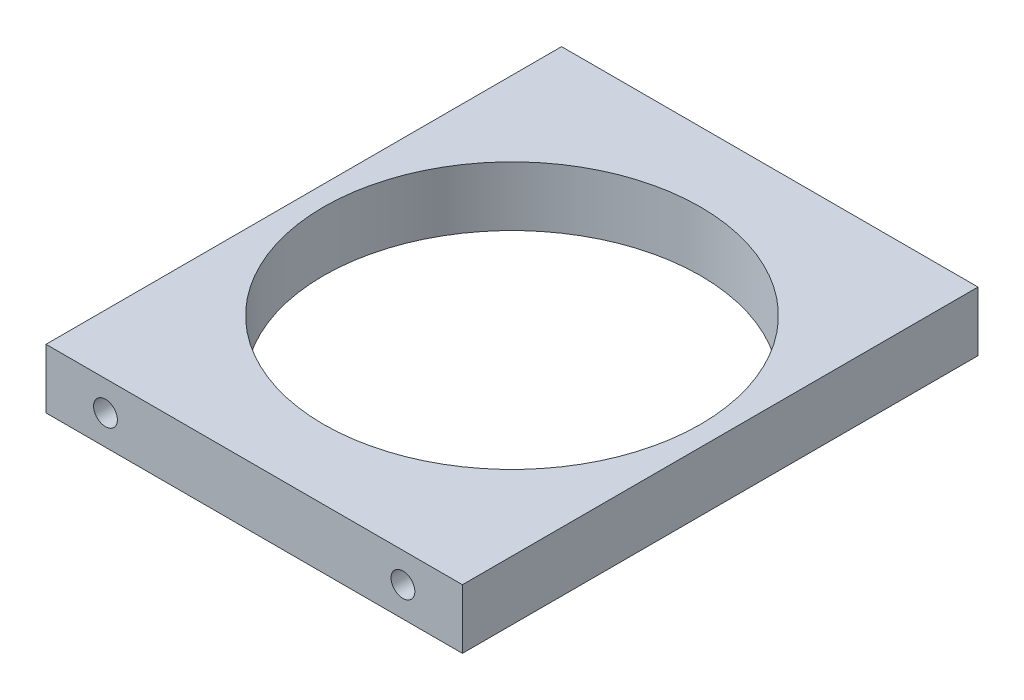
from build123d import *

# Parameters (mm, degrees)
SKETCH1_W           = 42
SKETCH1_H           = 52
BOSS_EXTRUDE1_DEPTH = 3
SKETCH2_R           = 19
CUT_EXTRUDE1_DEPTH  = 7
SKETCH3_R           = 1.2
CUT_EXTRUDE2_DEPTH  = 8
SKETCH4_R           = 1.2
CUT_EXTRUDE3_DEPTH  = 8


with BuildPart() as part:
    # Sketch1 → Boss-Extrude1 (new body, symmetric)
    with BuildSketch(Plane(origin=(0, 0, 0), x_dir=(1, 0, 0), z_dir=(0, 1, 0))):
        Rectangle(SKETCH1_W, SKETCH1_H)
    extrude(amount=BOSS_EXTRUDE1_DEPTH, both=True)

    # Sketch2 → Cut-Extrude1 (cut, through all)
    with BuildSketch(Plane(origin=(0, 3, 0), x_dir=(1, 0, 0), z_dir=(0, 1, 0))):
        Circle(SKETCH2_R)
    extrude(amount=-CUT_EXTRUDE1_DEPTH, mode=Mode.SUBTRACT)

    # Sketch3 → Cut-Extrude2 (cut)
    with BuildSketch(Plane(origin=(0, 0, -26), x_dir=(-1, 0, 0), z_dir=(0, 0, -1))):
        with Locations((-15, 0)):
            Circle(SKETCH3_R)
        with Locations((15, 0)):
            Circle(SKETCH3_R)
    extrude(amount=-CUT_EXTRUDE2_DEPTH, mode=Mode.SUBTRACT)

    # Sketch4 → Cut-Extrude3 (cut)
    with BuildSketch(Plane.XY.offset(26)):
        with Locations((15, 0)):
            Circle(SKETCH4_R)
        with Locations((-15, 0)):
            Circle(SKETCH4_R)
    extrude(amount=-CUT_EXTRUDE3_DEPTH, mode=Mode.SUBTRACT)


solid = part.part
